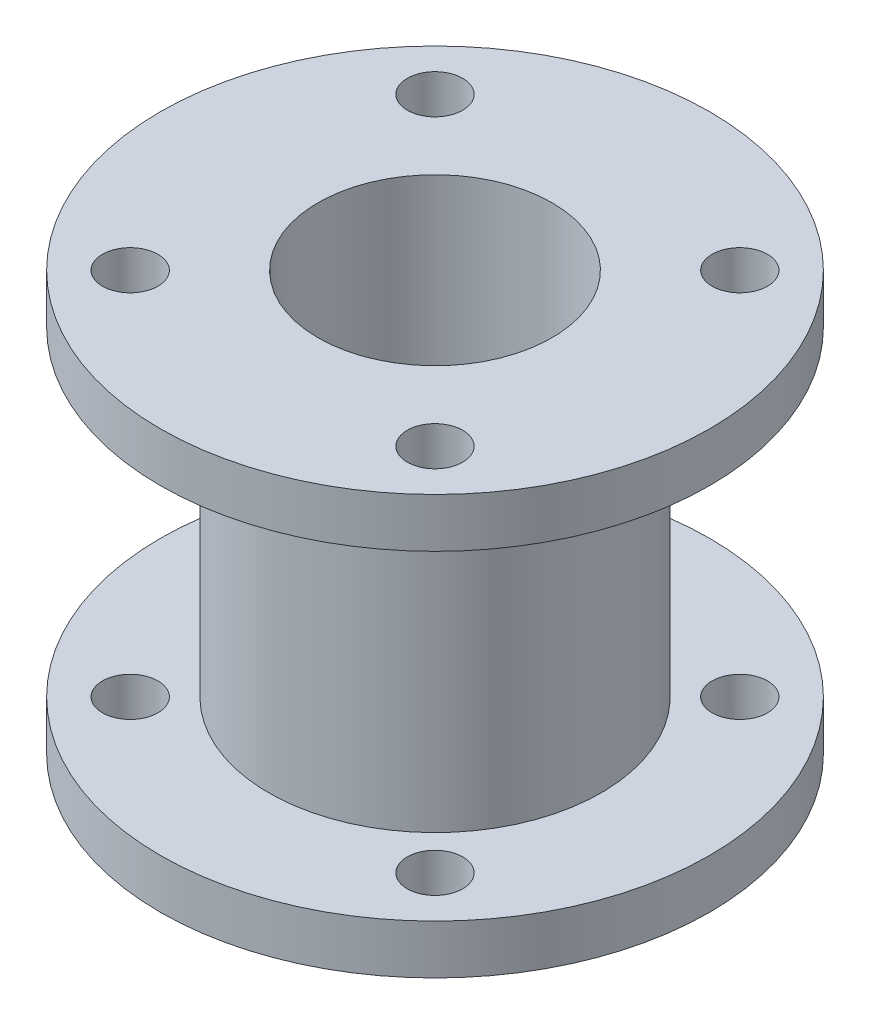
from build123d import *

# Parameters (mm, degrees)
M4_CLEARANCE_HOLE1_D = 4.5


with BuildPart() as part:
    # Sketch1 → Revolve1 (revolve)
    with BuildSketch(Plane.XY, mode=Mode.PRIVATE) as revolve1_sk:
        Polygon((13.5, 26), (22.3, 26), (22.3, 30), (9.5, 30), (9.5, -4), (22.3, -4), (22.3, 0), (13.5, 0), align=None)
    revolve(revolve1_sk.sketch.rotate(Axis((0, 0, 0), (0, 1, 0)), 90), axis=Axis((0, 0, 0), (0, 1, 0)))  # turned: the seam where the file's is

    # M4 Clearance Hole1 (through all)
    with Locations(Plane.XZ.offset(4)):
        with Locations((-12.374368671, 12.374368671), (12.374368671, 12.374368671), (12.374368671, -12.374368671), (-12.374368671, -12.374368671)):
            Hole(M4_CLEARANCE_HOLE1_D / 2)


solid = part.part
